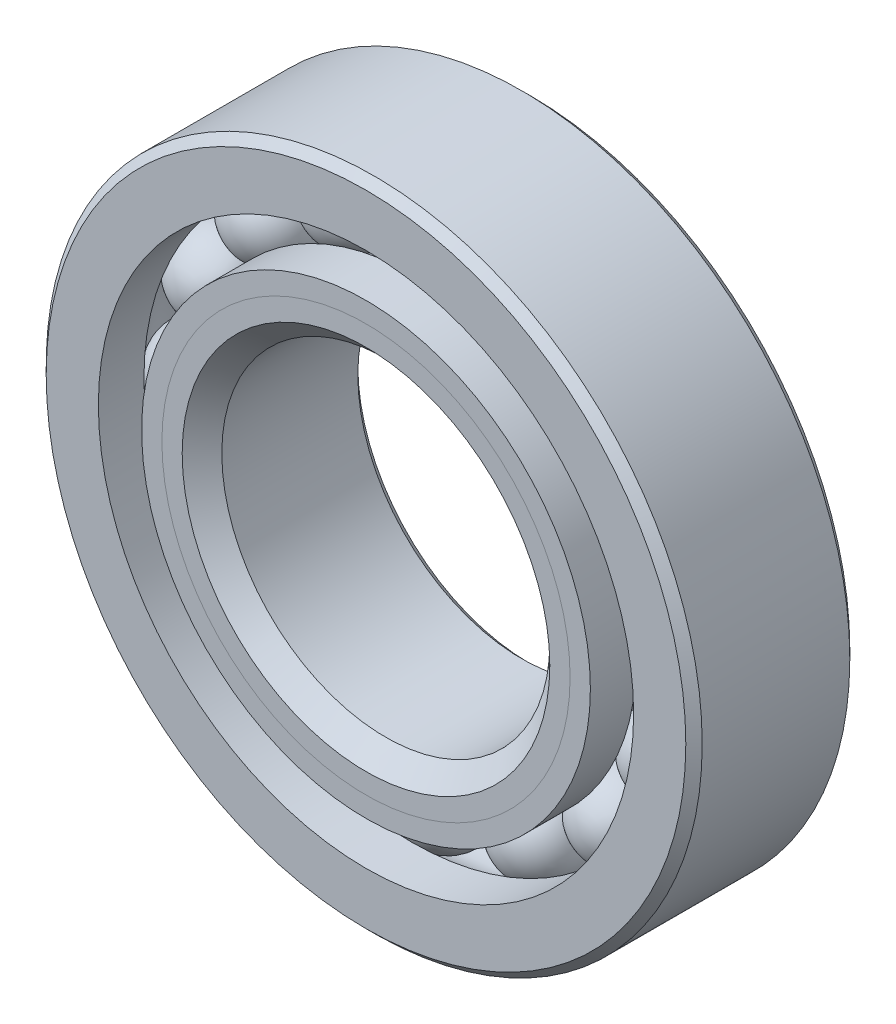
from build123d import *

# Parameters (mm, degrees)
CIRPATTERN1_COUNT = 16


with BuildPart() as part:
    # Sketch1 → Revolve1 (revolve)
    with BuildSketch(Plane(origin=(0, 0, 0), x_dir=(0, 0, -1), z_dir=(1, 0, 0)), mode=Mode.PRIVATE) as revolve1_sk:
        with BuildLine():
            Line((5.715, 25.4), (-5.715, 25.4))
            Line((-5.715, 25.4), (-6.35, 24.765))
            Line((-6.35, 24.765), (-6.35, 20.724725275))
            Line((-6.35, 20.724725275), (-2.822222222, 20.724725275))
            ThreePointArc((-2.822222222, 20.724725275), (0, 22.331713427), (2.822222222, 20.724725275))
            Line((2.822222222, 20.724725275), (6.35, 20.724725275))
            Line((6.35, 20.724725275), (6.35, 24.765))
            Line((6.35, 24.765), (5.715, 25.4))
        make_face()
    revolve(revolve1_sk.sketch.rotate(Axis((0, 0, 6.35), (0, 0, -1)), 90), axis=Axis((0, 0, 6.35), (0, 0, -1)))  # turned: the seam where the file's is


with BuildPart() as body_2:
    # Sketch2 → Revolve2 (revolve)
    with BuildSketch(Plane(origin=(0, 0, 0), x_dir=(0, 0, -1), z_dir=(1, 0, 0)), mode=Mode.PRIVATE) as revolve2_sk:
        with BuildLine():
            Line((-6.35, 17.375274725), (-2.822222222, 17.375274725))
            ThreePointArc((-2.822222222, 17.375274725), (-1.623834135, 16.198192552), (0, 15.768286573))
            Line((0, 15.768286573), (0, 14.234143286))
            Line((0, 14.234143286), (-4.779434281, 14.234143286))
            Line((-4.779434281, 14.234143286), (-6.35, 15.804709006))
            Line((-6.35, 15.804709006), (-6.35, 17.375274725))
        make_face()
    revolve(revolve2_sk.sketch.rotate(Axis((0, 0, 6.35), (0, 0, -1)), 90), axis=Axis((0, 0, 6.35), (0, 0, -1)))  # turned: the seam where the file's is


with BuildPart() as body_3:
    # Sketch3 → Revolve3 (revolve)
    with BuildSketch(Plane(origin=(0, 0, 0), x_dir=(0, 0, -1), z_dir=(1, 0, 0)), mode=Mode.PRIVATE) as revolve3_sk:
        with BuildLine():
            Line((-6.35, 15.804709006), (-4.779434281, 14.234143286))
            Line((-4.779434281, 14.234143286), (0, 14.234143286))
            Line((0, 14.234143286), (0, 15.768286573))
            ThreePointArc((0, 15.768286573), (1.623834135, 16.198192552), (2.822222222, 17.375274725))
            Line((2.822222222, 17.375274725), (6.35, 17.375274725))
            Line((6.35, 17.375274725), (6.35, 13.335))
            Line((6.35, 13.335), (5.715, 12.7))
            Line((5.715, 12.7), (-4.815856714, 12.7))
            Line((-4.815856714, 12.7), (-6.35, 14.234143286))
            Line((-6.35, 14.234143286), (-6.35, 15.804709006))
        make_face()
    revolve(revolve3_sk.sketch.rotate(Axis((0, 0, 6.35), (0, 0, -1)), 90), axis=Axis((0, 0, 6.35), (0, 0, -1)))  # turned: the seam where the file's is


with BuildPart() as body_4:
    # Sketch4 → Revolve4 (revolve)
    with BuildSketch(Plane(origin=(0, 0, 0), x_dir=(0, 0, -1), z_dir=(1, 0, 0))):
        with BuildLine():
            Line((-3.281713427, 19.05), (3.281713427, 19.05))
            ThreePointArc((3.281713427, 19.05), (0, 22.331713427), (-3.281713427, 19.05))
        make_face()
    revolve(axis=Axis((0, 19.05, 3.281713427), (0, 0, -1)))


with BuildPart() as cirpattern1_1:
    # CirPattern1: pattern copy
    add(body_4.part.rotate(Axis((0, 0, 0), (0, 0, 1)), 1 * 360 / CIRPATTERN1_COUNT))


with BuildPart() as cirpattern1_2:
    # CirPattern1: pattern copy
    add(body_4.part.rotate(Axis((0, 0, 0), (0, 0, 1)), 2 * 360 / CIRPATTERN1_COUNT))


with BuildPart() as cirpattern1_3:
    # CirPattern1: pattern copy
    add(body_4.part.rotate(Axis((0, 0, 0), (0, 0, 1)), 3 * 360 / CIRPATTERN1_COUNT))


with BuildPart() as cirpattern1_4:
    # CirPattern1: pattern copy
    add(body_4.part.rotate(Axis((0, 0, 0), (0, 0, 1)), 4 * 360 / CIRPATTERN1_COUNT))


with BuildPart() as cirpattern1_5:
    # CirPattern1: pattern copy
    add(body_4.part.rotate(Axis((0, 0, 0), (0, 0, 1)), 5 * 360 / CIRPATTERN1_COUNT))


with BuildPart() as cirpattern1_6:
    # CirPattern1: pattern copy
    add(body_4.part.rotate(Axis((0, 0, 0), (0, 0, 1)), 6 * 360 / CIRPATTERN1_COUNT))


with BuildPart() as cirpattern1_7:
    # CirPattern1: pattern copy
    add(body_4.part.rotate(Axis((0, 0, 0), (0, 0, 1)), 7 * 360 / CIRPATTERN1_COUNT))


with BuildPart() as cirpattern1_8:
    # CirPattern1: pattern copy
    add(body_4.part.rotate(Axis((0, 0, 0), (0, 0, 1)), 8 * 360 / CIRPATTERN1_COUNT))


with BuildPart() as cirpattern1_9:
    # CirPattern1: pattern copy
    add(body_4.part.rotate(Axis((0, 0, 0), (0, 0, 1)), 9 * 360 / CIRPATTERN1_COUNT))


with BuildPart() as cirpattern1_10:
    # CirPattern1: pattern copy
    add(body_4.part.rotate(Axis((0, 0, 0), (0, 0, 1)), 10 * 360 / CIRPATTERN1_COUNT))


with BuildPart() as cirpattern1_11:
    # CirPattern1: pattern copy
    add(body_4.part.rotate(Axis((0, 0, 0), (0, 0, 1)), 11 * 360 / CIRPATTERN1_COUNT))


with BuildPart() as cirpattern1_12:
    # CirPattern1: pattern copy
    add(body_4.part.rotate(Axis((0, 0, 0), (0, 0, 1)), 12 * 360 / CIRPATTERN1_COUNT))


with BuildPart() as cirpattern1_13:
    # CirPattern1: pattern copy
    add(body_4.part.rotate(Axis((0, 0, 0), (0, 0, 1)), 13 * 360 / CIRPATTERN1_COUNT))


with BuildPart() as cirpattern1_14:
    # CirPattern1: pattern copy
    add(body_4.part.rotate(Axis((0, 0, 0), (0, 0, 1)), 14 * 360 / CIRPATTERN1_COUNT))


with BuildPart() as cirpattern1_15:
    # CirPattern1: pattern copy
    add(body_4.part.rotate(Axis((0, 0, 0), (0, 0, 1)), 15 * 360 / CIRPATTERN1_COUNT))


solid = Compound([part.part, body_2.part, body_3.part, body_4.part, cirpattern1_1.part, cirpattern1_2.part, cirpattern1_3.part, cirpattern1_4.part, cirpattern1_5.part, cirpattern1_6.part, cirpattern1_7.part, cirpattern1_8.part, cirpattern1_9.part, cirpattern1_10.part, cirpattern1_11.part, cirpattern1_12.part, cirpattern1_13.part, cirpattern1_14.part, cirpattern1_15.part])
